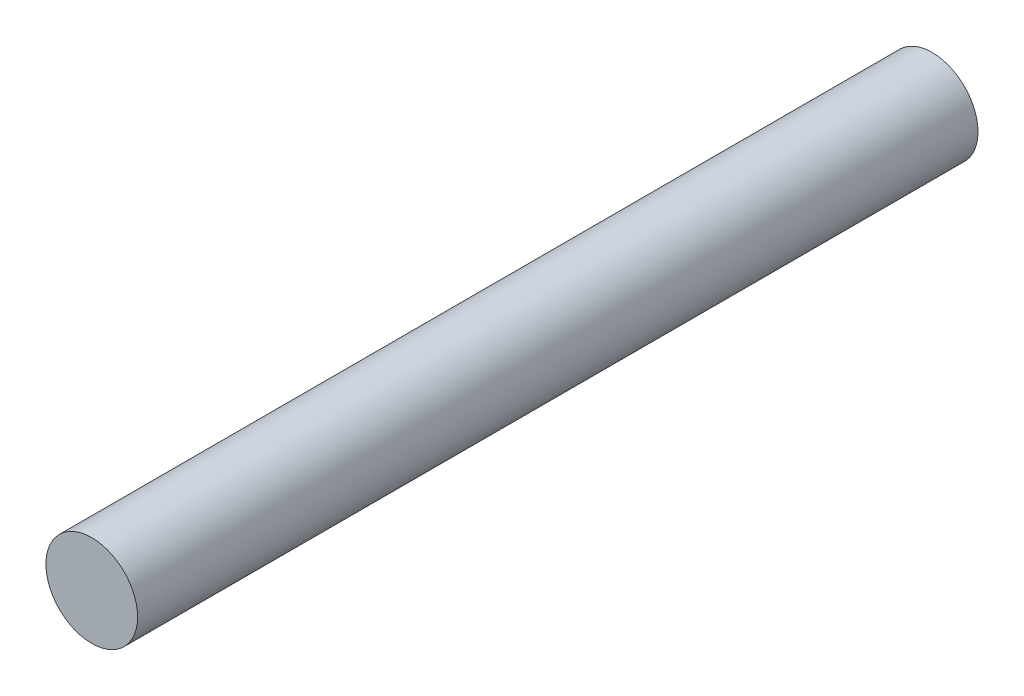
from build123d import *

# Parameters (mm, degrees)
SKETCH1_R           = 3
BOSS_EXTRUDE1_DEPTH = 55


with BuildPart() as part:
    # Sketch1 → Boss-Extrude1 (new body)
    with BuildSketch(Plane.XY):
        Circle(SKETCH1_R)
    extrude(amount=BOSS_EXTRUDE1_DEPTH)


solid = part.part
